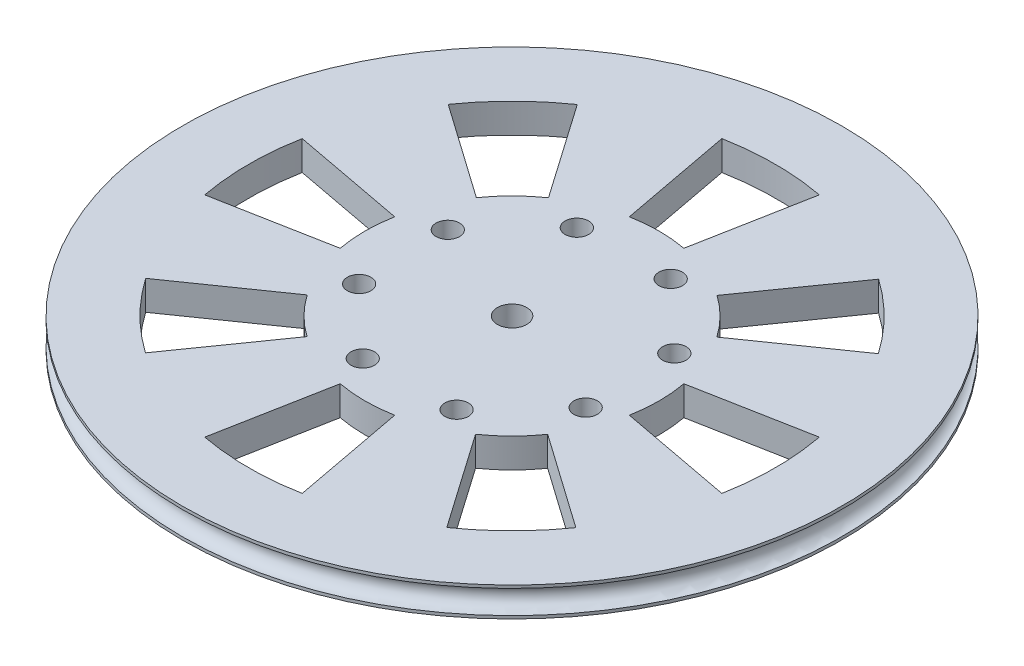
from build123d import *

# Parameters (mm, degrees)
SKETCH6_R                = 56
BOSS_EXTRUDE3_DEPTH      = 5
CUT_EXTRUDE4_DEPTH       = 80.353638858
CUT_EXTRUDE4_DEPTH_BACK  = 80.353638858
CUT_EXTRUDE5_DEPTH       = 80.353638858
CUT_EXTRUDE5_DEPTH_BACK  = 80.353638858
SKETCH7_8_R              = 2
SKETCH10_R               = 2
CUT_EXTRUDE14_DEPTH      = 80.353638858
CUT_EXTRUDE14_DEPTH_BACK = 5
SKETCH11_R               = 2.5
SKETCH12_R               = 9
BOSS_EXTRUDE4_DEPTH      = 4


with BuildPart() as part:
    # Sketch6 → Boss-Extrude3 (new body)
    with BuildSketch(Plane(origin=(0, 0, 0), x_dir=(1, 0, 0), z_dir=(0, 1, 0))):
        Circle(SKETCH6_R)
    extrude(amount=BOSS_EXTRUDE3_DEPTH)

    # Sketch7 → Cut-Extrude4 (cut, two sides: drawn at the far end of the back side and taken through both)
    with BuildSketch(Plane(origin=(0, 5, 0), x_dir=(1, 0, 0), z_dir=(0, 1, 0)).offset(-CUT_EXTRUDE4_DEPTH_BACK)):
        with BuildLine():
            ThreePointArc((43.937630618, -8.282785337), (44.711518844, 0), (43.937630618, 8.282785337))
            Line((43.937630618, 8.282785337), (24.567288114, 4.631236844))
            ThreePointArc((24.567288114, 4.631236844), (25, 0), (24.567288114, -4.631236844))
            Line((24.567288114, -4.631236844), (43.937630618, -8.282785337))
        make_face()
        with BuildLine():
            Line((20.503283661, 14.304382514), (36.669318151, 25.582826732))
            ThreePointArc((36.669318151, 25.582826732), (31.677302024, 31.554214517), (25.725394502, 36.569440726))
            Line((25.725394502, 36.569440726), (14.384097861, 20.447438195))
            ThreePointArc((14.384097861, 20.447438195), (17.712047613, 17.64322446), (20.503283661, 14.304382514))
        make_face()
        with BuildLine():
            ThreePointArc((25.582826732, -36.669318151), (31.554214517, -31.677302024), (36.569440726, -25.725394502))
            Line((36.569440726, -25.725394502), (20.447438195, -14.384097861))
            ThreePointArc((20.447438195, -14.384097861), (17.64322446, -17.712047613), (14.304382514, -20.503283661))
            Line((14.304382514, -20.503283661), (25.582826732, -36.669318151))
        make_face()
        with BuildLine():
            Line((4.631236844, 24.567288114), (8.282785337, 43.937630618))
            ThreePointArc((8.282785337, 43.937630618), (0, 44.711518844), (-8.282785337, 43.937630618))
            Line((-8.282785337, 43.937630618), (-4.631236844, 24.567288114))
            ThreePointArc((-4.631236844, 24.567288114), (0, 25), (4.631236844, 24.567288114))
        make_face()
        with BuildLine():
            ThreePointArc((-8.282785337, -43.937630618), (0, -44.711518844), (8.282785337, -43.937630618))
            Line((8.282785337, -43.937630618), (4.631236844, -24.567288114))
            ThreePointArc((4.631236844, -24.567288114), (0, -25), (-4.631236844, -24.567288114))
            Line((-4.631236844, -24.567288114), (-8.282785337, -43.937630618))
        make_face()
        with BuildLine():
            Line((-14.304382514, 20.503283661), (-25.582826732, 36.669318151))
            ThreePointArc((-25.582826732, 36.669318151), (-31.554214517, 31.677302024), (-36.569440726, 25.725394502))
            Line((-36.569440726, 25.725394502), (-20.447438195, 14.384097861))
            ThreePointArc((-20.447438195, 14.384097861), (-17.64322446, 17.712047613), (-14.304382514, 20.503283661))
        make_face()
        with BuildLine():
            ThreePointArc((-36.669318151, -25.582826732), (-31.677302024, -31.554214517), (-25.725394502, -36.569440726))
            Line((-25.725394502, -36.569440726), (-14.384097861, -20.447438195))
            ThreePointArc((-14.384097861, -20.447438195), (-17.712047613, -17.64322446), (-20.503283661, -14.304382514))
            Line((-20.503283661, -14.304382514), (-36.669318151, -25.582826732))
        make_face()
        with BuildLine():
            Line((-24.567288114, 4.631236844), (-43.937630618, 8.282785337))
            ThreePointArc((-43.937630618, 8.282785337), (-44.711518844, 0), (-43.937630618, -8.282785337))
            Line((-43.937630618, -8.282785337), (-24.567288114, -4.631236844))
            ThreePointArc((-24.567288114, -4.631236844), (-25, 0), (-24.567288114, 4.631236844))
        make_face()
    extrude(amount=CUT_EXTRUDE4_DEPTH + CUT_EXTRUDE4_DEPTH_BACK, mode=Mode.SUBTRACT)

    # Sketch7_8 → Cut-Extrude5 (cut, two sides: drawn at the far end of the back side and taken through both)
    with BuildSketch(Plane(origin=(0, 5, 0), x_dir=(1, 0, 0), z_dir=(0, 1, 0)).offset(-CUT_EXTRUDE5_DEPTH_BACK)):
        with Locations((19.298680627, 8.282785337)):
            Circle(SKETCH7_8_R)
        with Locations((19.736681401, -7.225357928)):
            Circle(SKETCH7_8_R)
        with Locations((8.023054044, 18.938985285)):
            Circle(SKETCH7_8_R)
        with Locations((9.080481453, -18.500984511)):
            Circle(SKETCH7_8_R)
        with Locations((-7.485089221, 18.500984511)):
            Circle(SKETCH7_8_R)
        with Locations((-6.427661812, -18.938985285)):
            Circle(SKETCH7_8_R)
        with Locations((-18.141289169, 7.225357928)):
            Circle(SKETCH7_8_R)
        with Locations((-17.703288395, -8.282785337)):
            Circle(SKETCH7_8_R)
    extrude(amount=CUT_EXTRUDE5_DEPTH + CUT_EXTRUDE5_DEPTH_BACK, mode=Mode.SUBTRACT)

    # Sketch10 → Cut-Revolve1 (revolve, cut)
    with BuildSketch(Plane.XY):
        with Locations((56, 2.5)):
            Circle(SKETCH10_R)
    revolve(axis=Axis((0, 40.614262211, 0), (0, -1, 0)), mode=Mode.SUBTRACT)

    # Sketch11 → Cut-Extrude14 (cut, two sides: drawn at the far end of the back side and taken through both)
    with BuildSketch(Plane(origin=(0, 0, 0), x_dir=(1, 0, 0), z_dir=(0, 1, 0)).offset(-CUT_EXTRUDE14_DEPTH_BACK)):
        Circle(SKETCH11_R)
    extrude(amount=CUT_EXTRUDE14_DEPTH + CUT_EXTRUDE14_DEPTH_BACK, mode=Mode.SUBTRACT)

    # Sketch12 → Boss-Extrude4 (add)
    with BuildSketch(Plane(origin=(0, 0, 0), x_dir=(1, 0, 0), z_dir=(0, 1, 0))):
        Circle(SKETCH12_R)
        Polygon((0, 7), (-6.062177826, 3.5), (-6.062177826, -3.5), (0, -7), (6.062177826, -3.5), (6.062177826, 3.5), align=None, mode=Mode.SUBTRACT)
    extrude(amount=-BOSS_EXTRUDE4_DEPTH)


solid = part.part
